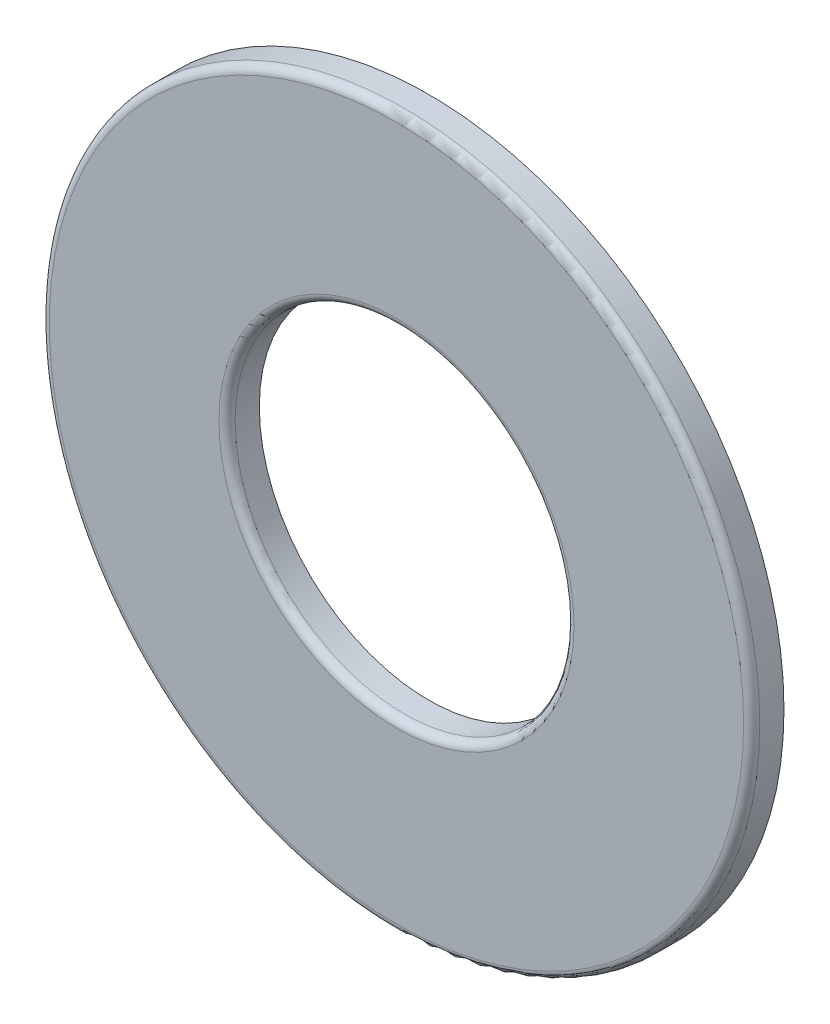
from build123d import *

# Parameters (mm, degrees)
SKETCH3_R                = 34.925
SKETCH3_R_2              = 16.6624
BOSS_EXTRUDE1_DEPTH      = 1.5875
BOSS_EXTRUDE1_DEPTH_BACK = 1.5875
FILLET1_R                = 0.79375


with BuildPart() as part:
    # Sketch3 → Boss-Extrude1 (new body, two sides)
    with BuildSketch(Plane.XY) as boss_extrude1_sk:
        Circle(SKETCH3_R)
        Circle(SKETCH3_R_2, mode=Mode.SUBTRACT)
    extrude(amount=BOSS_EXTRUDE1_DEPTH)
    extrude(boss_extrude1_sk.sketch, amount=-BOSS_EXTRUDE1_DEPTH_BACK)

    # Fillet1
    fillet1_edges = [part.edges().sort_by_distance(p)[0] for p in [
        (-34.925, 0, 1.5875),
        (-16.6624, 0, 1.5875),
    ]]
    fillet(fillet1_edges, radius=FILLET1_R)


solid = part.part
